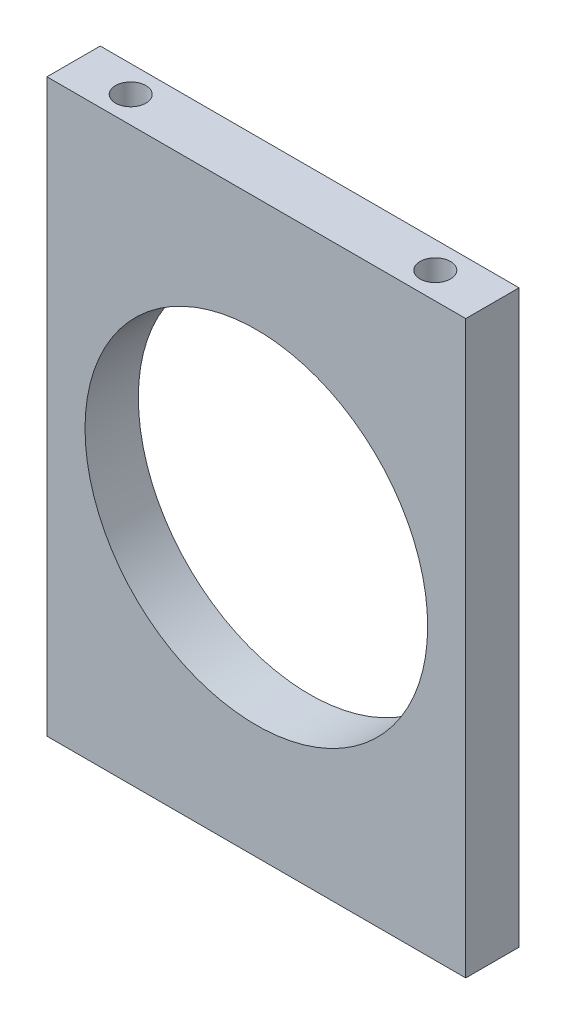
from build123d import *

# Parameters (mm, degrees)
SKETCH1_W           = 55
SKETCH1_H           = 75
SKETCH1_R           = 22.5
BOSS_EXTRUDE1_DEPTH = 7
SKETCH2_R           = 2
CUT_EXTRUDE1_DEPTH  = 15
SKETCH3_R           = 2
CUT_EXTRUDE2_DEPTH  = 15


with BuildPart() as part:
    # Sketch1 → Boss-Extrude1 (new body)
    with BuildSketch(Plane.XY):
        Rectangle(SKETCH1_W, SKETCH1_H)
        Circle(SKETCH1_R, mode=Mode.SUBTRACT)
    extrude(amount=BOSS_EXTRUDE1_DEPTH)

    # Sketch2 → Cut-Extrude1 (cut)
    with BuildSketch(Plane(origin=(0, 37.5, 0), x_dir=(1, 0, 0), z_dir=(0, 1, 0))):
        with Locations((-20, -3.5)):
            Circle(SKETCH2_R)
        with Locations((20, -3.5)):
            Circle(SKETCH2_R)
    extrude(amount=-CUT_EXTRUDE1_DEPTH, mode=Mode.SUBTRACT)

    # Sketch3 → Cut-Extrude2 (cut)
    with BuildSketch(Plane.XZ.offset(37.5)):
        with Locations((-20, 3.5)):
            Circle(SKETCH3_R)
        with Locations((20, 3.5)):
            Circle(SKETCH3_R)
    extrude(amount=-CUT_EXTRUDE2_DEPTH, mode=Mode.SUBTRACT)


solid = part.part
